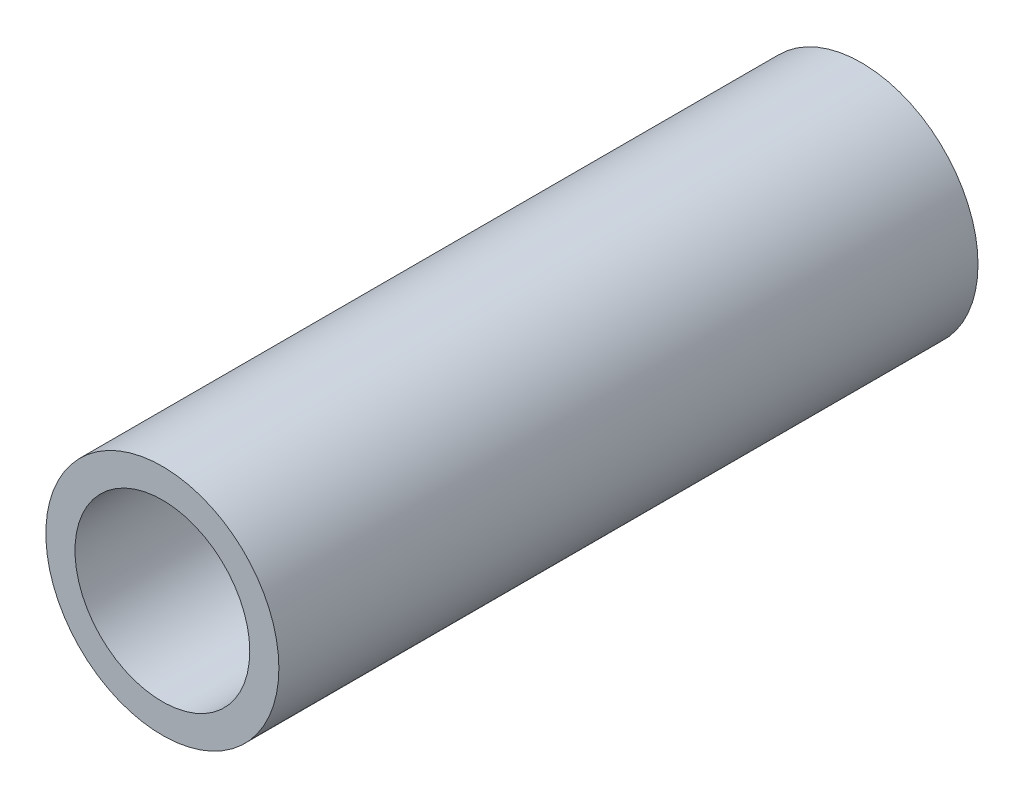
from build123d import *

# Parameters (mm, degrees)
CROQUIS1_R              = 20
CROQUIS1_R_2            = 15
SALIENTE_EXTRUIR1_DEPTH = 120


with BuildPart() as part:
    # Croquis1 → Saliente-Extruir1 (new body)
    with BuildSketch(Plane.XY):
        Circle(CROQUIS1_R)
        Circle(CROQUIS1_R_2, mode=Mode.SUBTRACT)
    extrude(amount=SALIENTE_EXTRUIR1_DEPTH)


solid = part.part
